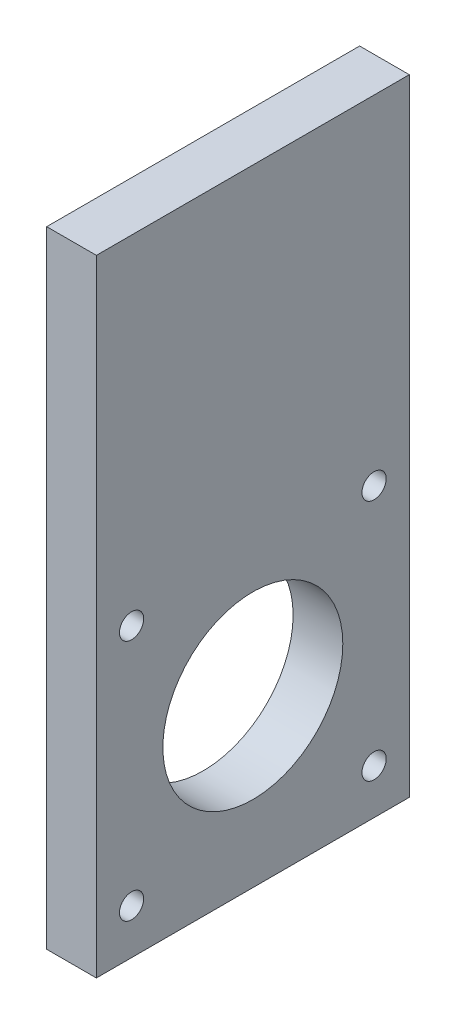
from build123d import *

# Parameters (mm, degrees)
SKETCH1_W               = 20
SKETCH1_H               = 80
BOSS_EXTRUDE1_DEPTH     = 6.35
SKETCH2_R               = 1.55
MOTOR_MOUNT_HOLES_DEPTH = 10
SKETCH3_R               = 11.5
FLANGE_HOLE_DEPTH       = 10


with BuildPart() as part:
    # Sketch1 → Boss-Extrude1 (new body)
    with BuildSketch(Plane(origin=(0, 0, 0), x_dir=(0, 0, -1), z_dir=(1, 0, 0))):
        with Locations((-10, 40)):
            Rectangle(SKETCH1_W, SKETCH1_H)
    boss_extrude1 = extrude(amount=BOSS_EXTRUDE1_DEPTH)

    # Sketch2 → Motor Mount Holes (cut)
    with BuildSketch(Plane(origin=(6.35, 0, 0), x_dir=(0, 0, -1), z_dir=(1, 0, 0))):
        with Locations((-15.5, 5.75)):
            Circle(SKETCH2_R)
        with Locations((-15.5, 36.75)):
            Circle(SKETCH2_R)
    motor_mount_holes = extrude(amount=-MOTOR_MOUNT_HOLES_DEPTH, mode=Mode.SUBTRACT)

    # Sketch3 → Flange Hole (cut)
    with BuildSketch(Plane(origin=(6.35, 0, 0), x_dir=(0, 0, -1), z_dir=(1, 0, 0))):
        with Locations((0, 21.25)):
            Circle(SKETCH3_R)
    flange_hole = extrude(amount=-FLANGE_HOLE_DEPTH, mode=Mode.SUBTRACT)

    # Mirror1: Boss-Extrude1, Motor Mount Holes, Flange Hole across plane
    add(boss_extrude1.mirror(Plane(origin=(6.35, 0, 0), x_dir=(1, 0, 0), z_dir=(0, 0, 1))))
    add(motor_mount_holes.mirror(Plane(origin=(6.35, 0, 0), x_dir=(1, 0, 0), z_dir=(0, 0, 1))), mode=Mode.SUBTRACT)
    add(flange_hole.mirror(Plane(origin=(6.35, 0, 0), x_dir=(1, 0, 0), z_dir=(0, 0, 1))), mode=Mode.SUBTRACT)


solid = part.part
